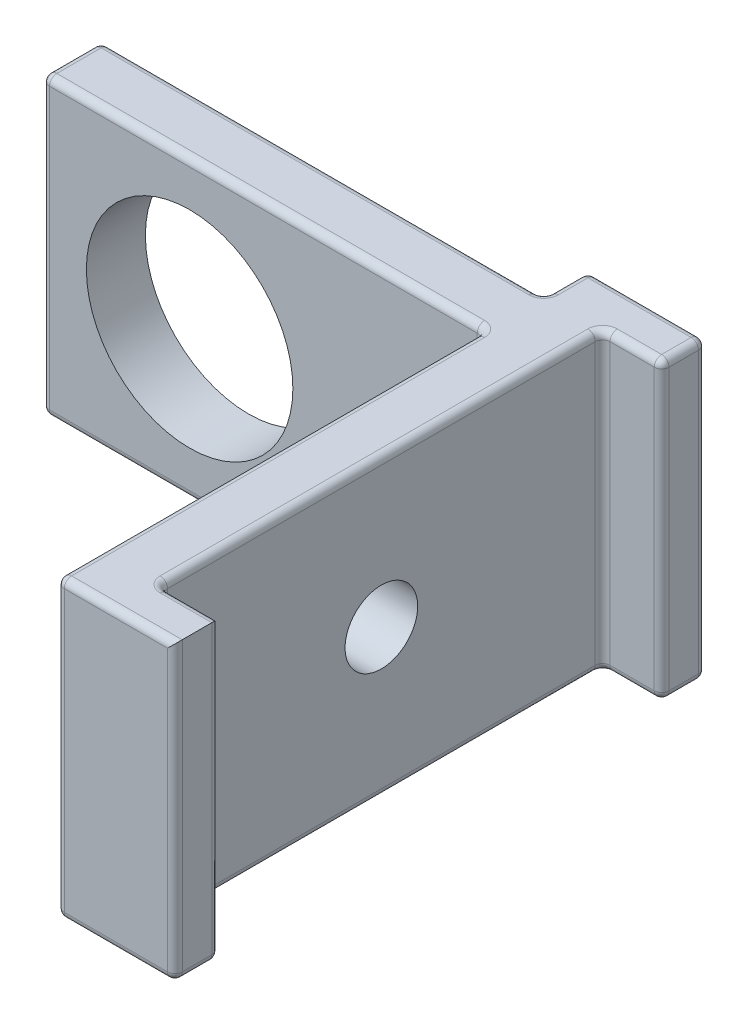
from build123d import *

# Parameters (mm, degrees)
SCHIZZO1_W                   = 30
SCHIZZO1_H                   = 20
SCHIZZO1_R                   = 7
ESTRUSIONE_ESTRUSIONE1_DEPTH = 4
SCHIZZO2_W                   = 4
SCHIZZO2_H                   = 20
ESTRUSIONE_ESTRUSIONE2_DEPTH = 30
SCHIZZO3_W                   = 8
SCHIZZO3_H                   = 20
ESTRUSIONE_ESTRUSIONE3_DEPTH = 3
SCHIZZO4_W                   = 8
SCHIZZO4_H                   = 20
ESTRUSIONE_ESTRUSIONE4_DEPTH = 3
RACCORDO1_R                  = 0.5
RACCORDO2_R                  = 0.5
RACCORDO3_R                  = 0.5
RACCORDO4_R                  = 0.5
RACCORDO5_R                  = 0.5
SCHIZZO5_R                   = 2.462201362
TAGLIO_ESTRUSIONE1_DEPTH     = 5


with BuildPart() as part:
    # Schizzo1 → Estrusione-Estrusione1 (new body)
    with BuildSketch(Plane.XY):
        with Locations((5, 0)):
            Rectangle(SCHIZZO1_W, SCHIZZO1_H)
        Circle(SCHIZZO1_R, mode=Mode.SUBTRACT)
    extrude(amount=ESTRUSIONE_ESTRUSIONE1_DEPTH)

    # Schizzo2 → Estrusione-Estrusione2 (add)
    with BuildSketch(Plane(origin=(0, 0, 0), x_dir=(-1, 0, 0), z_dir=(0, 0, -1))):
        with Locations((-22, 0)):
            Rectangle(SCHIZZO2_W, SCHIZZO2_H)
    extrude(amount=-ESTRUSIONE_ESTRUSIONE2_DEPTH)

    # Schizzo3 → Estrusione-Estrusione3 (add)
    with BuildSketch(Plane.XY.offset(30)):
        with Locations((24, 0)):
            Rectangle(SCHIZZO3_W, SCHIZZO3_H)
    extrude(amount=ESTRUSIONE_ESTRUSIONE3_DEPTH)

    # Schizzo4 → Estrusione-Estrusione4 (add)
    with BuildSketch(Plane(origin=(0, 0, 0), x_dir=(-1, 0, 0), z_dir=(0, 0, -1))):
        with Locations((-24, 0)):
            Rectangle(SCHIZZO4_W, SCHIZZO4_H)
    extrude(amount=ESTRUSIONE_ESTRUSIONE4_DEPTH)

    # Raccordo1
    raccordo1_edges = [part.edges().sort_by_distance(p)[0] for p in [
        (20, 0, 4),
        (24, 0, 30),
        (24, 0, 0),
        (20, 0, 0),
    ]]
    fillet(raccordo1_edges, radius=RACCORDO1_R)

    # Raccordo2
    raccordo2_edges = [part.edges().sort_by_distance(p)[0] for p in [
        (4.75, -10, 0),
        (20, -10, -1.75),
        (4.75, 10, 0),
        (19.853553391, 10, -0.146446609),
        (19.853553391, -10, -0.146446609),
        (28, 0, 0),
        (20, 10, -1.75),
    ]]
    fillet(raccordo2_edges, radius=RACCORDO2_R)

    # Raccordo3
    raccordo3_edges = [part.edges().sort_by_distance(p)[0] for p in [
        (26.25, -10, 30),
        (24, -10, 15),
        (28, -10, -1.75),
        (27.853553391, -10, -0.146446609),
        (24.146446609, -10, 29.853553391),
        (24.146446609, -10, 0.146446609),
        (26, -10, 0),
    ]]
    fillet(raccordo3_edges, radius=RACCORDO3_R)

    # Raccordo4
    raccordo4_edges = [part.edges().sort_by_distance(p)[0] for p in [
        (28, 0.25, 30),
        (28, -9.853553391, 30.146446609),
        (28, -10, 31.75),
        (26.25, 10, 30),
        (24, 10, 15),
        (28, 10, -1.75),
        (27.853553391, 10, -0.146446609),
        (24.146446609, 10, 29.853553391),
        (24.146446609, 10, 0.146446609),
        (26, 10, 0),
    ]]
    fillet(raccordo4_edges, radius=RACCORDO4_R)

    # Raccordo5
    raccordo5_edges = [part.edges().sort_by_distance(p)[0] for p in [
        (20, 0, -3),
        (20.146446609, -9.853553391, -3),
        (20.146446609, 9.853553391, -3),
        (24, -10, -3),
        (27.853553391, -9.853553391, -3),
        (28, 0.25, 33),
        (28, 0, -3),
        (27.853553391, 9.853553391, -3),
        (27.853553391, -9.853553391, 33),
        (20, 10, 18.75),
        (20, -10, 18.75),
        (20, 0, 33),
        (23.75, -10, 33),
        (24, 10, 33),
        (-10, 0, 4),
        (4.75, 10, 4),
        (19.853553391, 10, 4.146446609),
        (19.853553391, -10, 4.146446609),
        (-10, 10, 2.25),
        (-10, -10, 2.25),
        (4.75, -10, 4),
        (24, 10, -3),
        (-10, 0, 0),
        (-10, -9.853553391, 0.146446609),
        (-10, 9.853553391, 0.146446609),
    ]]
    fillet(raccordo5_edges, radius=RACCORDO5_R)

    # Schizzo5 → Taglio-Estrusione1 (cut)
    with BuildSketch(Plane(origin=(24, 0, 0), x_dir=(0, 0, -1), z_dir=(1, 0, 0))):
        with Locations((-15, 0)):
            Circle(SCHIZZO5_R)
    extrude(amount=-TAGLIO_ESTRUSIONE1_DEPTH, mode=Mode.SUBTRACT)


solid = part.part
